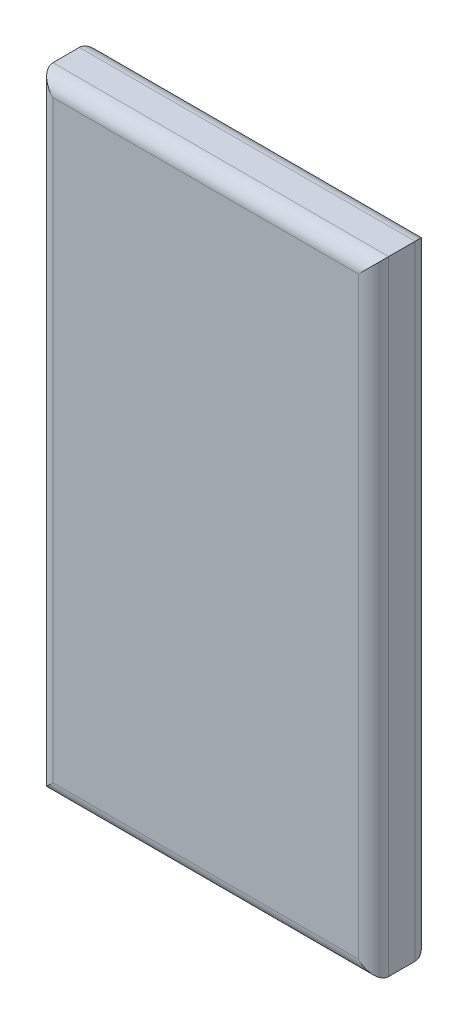
from build123d import *

# Parameters (mm, degrees)
SKETCH1_W           = 17.78
SKETCH1_H           = 33.02
BOSS_EXTRUDE1_DEPTH = 3
FILLET2_R           = 0.8


with BuildPart() as part:
    # Sketch1 → Boss-Extrude1 (new body)
    with BuildSketch(Plane.XY):
        with Locations((8.89, 16.51)):
            Rectangle(SKETCH1_W, SKETCH1_H)
    extrude(amount=BOSS_EXTRUDE1_DEPTH)

    # Fillet2
    fillet2_edges = [part.edges().sort_by_distance(p)[0] for p in [
        (17.78, 16.51, 3),
        (8.89, 33.02, 3),
        (0, 16.51, 3),
        (8.89, 33.02, 0),
        (17.78, 16.51, 0),
        (8.89, 0, 0),
        (0, 16.51, 0),
        (8.89, 0, 3),
    ]]
    fillet(fillet2_edges, radius=FILLET2_R)


solid = part.part
